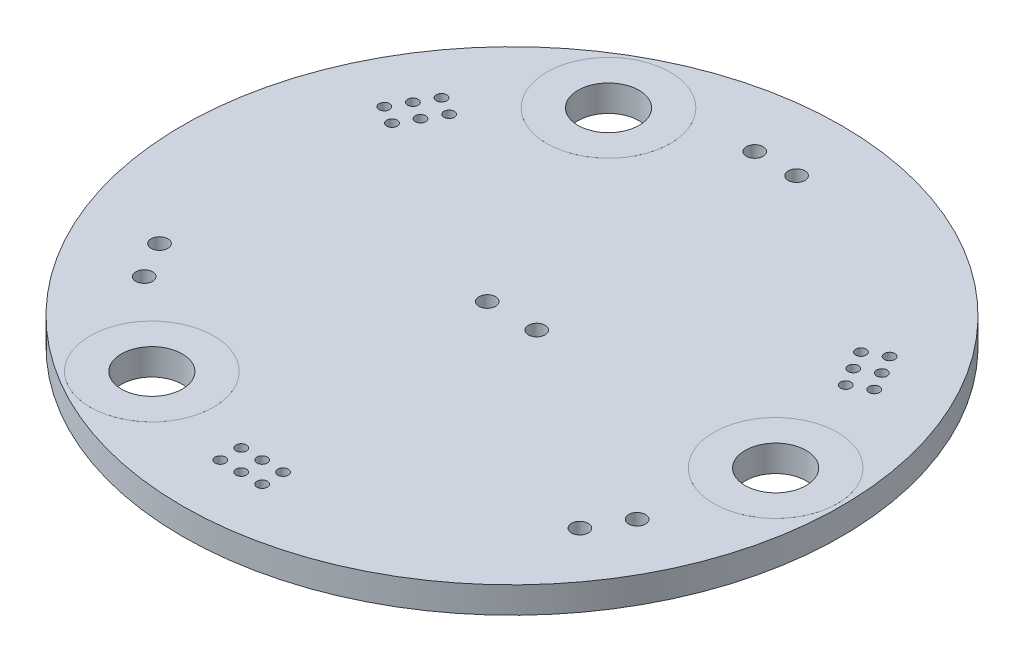
from build123d import *

# Parameters (mm, degrees)
SKETCH1_R           = 20
BOSS_EXTRUDE1_DEPTH = 1.6
SKETCH2_R           = 1.85
CUT_EXTRUDE1_DEPTH  = 29.329489935
SKETCH3_R           = 0.508
SKETCH3_R_2         = 0.3175
CUT_EXTRUDE2_DEPTH  = 29.329489935
BOSS_EXTRUDE2_START = 0.001
SKETCH5_R           = 3.75
SKETCH5_R_2         = 1.85
BOSS_EXTRUDE2_DEPTH = 0.001
BOSS_EXTRUDE3_DEPTH = 0.001


with BuildPart() as part:
    # Sketch1 → Boss-Extrude1 (new body)
    with BuildSketch(Plane(origin=(0, 0, 0), x_dir=(1, 0, 0), z_dir=(0, 1, 0))):
        Circle(SKETCH1_R)
    extrude(amount=BOSS_EXTRUDE1_DEPTH)

    # Sketch2 → Cut-Extrude1 (cut, through all)
    with BuildSketch(Plane(origin=(0, 1.6, 0), x_dir=(1, 0, 0), z_dir=(0, 1, 0))):
        with Locations((16, 0)):
            Circle(SKETCH2_R)
        with Locations((-8, -13.856406461)):
            Circle(SKETCH2_R)
        with Locations((-8, 13.856406461)):
            Circle(SKETCH2_R)
    extrude(amount=-CUT_EXTRUDE1_DEPTH, mode=Mode.SUBTRACT)

    # Sketch3 → Cut-Extrude2 (cut, through all)
    with BuildSketch(Plane(origin=(0, 1.6, 0), x_dir=(1, 0, 0), z_dir=(0, 1, 0))):
        with Locations((-1.5, 0)):
            Circle(SKETCH3_R)
        with Locations((1.5, 0)):
            Circle(SKETCH3_R)
        with Locations((1.27, 16)):
            Circle(SKETCH3_R)
        with Locations((-1.27, 16)):
            Circle(SKETCH3_R)
        with Locations((13.221406461, -9.099852263)):
            Circle(SKETCH3_R)
        with Locations((14.491406461, -6.900147737)):
            Circle(SKETCH3_R)
        with Locations((-14.491406461, -6.900147737)):
            Circle(SKETCH3_R)
        with Locations((-13.221406461, -9.099852263)):
            Circle(SKETCH3_R)
        with Locations((1.27, -16.4332)):
            Circle(SKETCH3_R_2)
        with Locations((1.27, -15.1632)):
            Circle(SKETCH3_R_2)
        with Locations((0, -15.1632)):
            Circle(SKETCH3_R_2)
        with Locations((-1.27, -15.1632)):
            Circle(SKETCH3_R_2)
        with Locations((0, -16.4332)):
            Circle(SKETCH3_R_2)
        with Locations((-1.27, -16.4332)):
            Circle(SKETCH3_R_2)
        with Locations((-14.866568665, 7.116747737)):
            Circle(SKETCH3_R_2)
        with Locations((-13.766716403, 6.481747737)):
            Circle(SKETCH3_R_2)
        with Locations((-13.131716403, 7.5816)):
            Circle(SKETCH3_R_2)
        with Locations((-12.496716403, 8.681452263)):
            Circle(SKETCH3_R_2)
        with Locations((-14.231568665, 8.2166)):
            Circle(SKETCH3_R_2)
        with Locations((-13.596568665, 9.316452263)):
            Circle(SKETCH3_R_2)
        with Locations((13.596568665, 9.316452263)):
            Circle(SKETCH3_R_2)
        with Locations((12.496716403, 8.681452263)):
            Circle(SKETCH3_R_2)
        with Locations((13.131716403, 7.5816)):
            Circle(SKETCH3_R_2)
        with Locations((13.766716403, 6.481747737)):
            Circle(SKETCH3_R_2)
        with Locations((14.231568665, 8.2166)):
            Circle(SKETCH3_R_2)
        with Locations((14.866568665, 7.116747737)):
            Circle(SKETCH3_R_2)
    extrude(amount=-CUT_EXTRUDE2_DEPTH, mode=Mode.SUBTRACT)

    # Sketch5 → Boss-Extrude2 (add)
    # profile 1 of 3: a face of its own
    with BuildSketch(Plane(origin=(0, 1.6, 0), x_dir=(1, 0, 0), z_dir=(0, 1, 0)).offset(BOSS_EXTRUDE2_START)):
        with Locations((-8, -13.856406461)):
            Circle(SKETCH5_R)
        with Locations((-8, -13.856406461)):
            Circle(SKETCH5_R_2, mode=Mode.SUBTRACT)
    # profile 2 of 3: a face of its own
    with BuildSketch(Plane(origin=(0, 1.6, 0), x_dir=(1, 0, 0), z_dir=(0, 1, 0)).offset(BOSS_EXTRUDE2_START)):
        with Locations((-8, 13.856406461)):
            Circle(SKETCH5_R)
        with Locations((-8, 13.856406461)):
            Circle(SKETCH5_R_2, mode=Mode.SUBTRACT)
    # profile 3 of 3: a face of its own
    with BuildSketch(Plane(origin=(0, 1.6, 0), x_dir=(1, 0, 0), z_dir=(0, 1, 0)).offset(BOSS_EXTRUDE2_START)):
        with Locations((16, 0)):
            Circle(SKETCH5_R)
        with Locations((16, 0)):
            Circle(SKETCH5_R_2, mode=Mode.SUBTRACT)
    boss_extrude2 = extrude(amount=-BOSS_EXTRUDE2_DEPTH)

    # Mirror1: Boss-Extrude2 across plane
    add(boss_extrude2.mirror(Plane.ZX.offset(0.8)))

    # Sketch6 → Boss-Extrude3 (add)
    # profile 1 of 7: a face of its own
    with BuildSketch(Plane(origin=(0, 0, 0), x_dir=(1, 0, 0), z_dir=(0, 1, 0))):
        with BuildLine():
            Line((-6.907051282, 6.560937956), (-7.394831731, 6.560937956))
            add(Edge.make_bspline(
                [(-7.394831731, 6.560937956), (-7.418709215, 6.56081242), (-7.464989723, 6.5605691), (-7.532289324, 6.556795435), (-7.595324189, 6.551649956), (-7.654112597, 6.543485604), (-7.708627385, 6.533634335), (-7.75903284, 6.521704466), (-7.805168677, 6.507399742), (-7.860249203, 6.484652399), (-7.923049675, 6.450850135), (-7.991048527, 6.40090116), (-8.049194413, 6.339806544), (-8.099327496, 6.270890361), (-8.139185439, 6.195079096), (-8.168020651, 6.114179675), (-8.186276277, 6.029235574), (-8.18815373, 5.970919018), (-8.189102564, 5.94144677)],
                knots=[0, 0, 0, 0, 1.001505555, 1.941167018, 2.826882275, 3.653841531, 4.429895133, 5.150066043, 5.825578002, 6.45369114, 7.647487171, 8.808567382, 9.977351308, 11.170798116, 12.373658725, 13.556498008, 14.765093433, 16, 16, 16, 16], degree=3))
            add(Edge.make_bspline(
                [(-8.189102564, 5.94144677), (-8.188321694, 5.913837802), (-8.18678721, 5.859583575), (-8.17211381, 5.78023064), (-8.149141904, 5.704694055), (-8.117209584, 5.633249494), (-8.075708158, 5.567511199), (-8.026523644, 5.506948866), (-7.967183071, 5.454126683), (-7.922723614, 5.424596038), (-7.900140224, 5.409595808)],
                knots=[0, 0, 0, 0, 1.044552857, 2.05264487, 3.044412934, 4.028983338, 5.005914585, 5.980388656, 6.974128949, 8, 8, 8, 8], degree=3))
            add(Edge.make_bspline(
                [(-7.900140224, 5.409595808), (-7.92854053, 5.398692238), (-7.982877349, 5.377831006), (-8.057653073, 5.340948532), (-8.122077962, 5.300832739), (-8.176647352, 5.257024274), (-8.223317105, 5.209803695), (-8.264069206, 5.158478613), (-8.298841617, 5.102379501), (-8.328636562, 5.042091261), (-8.351885673, 4.978229498), (-8.369297034, 4.911393229), (-8.379273783, 4.841822119), (-8.380693527, 4.794475419), (-8.381410256, 4.770573373)],
                knots=[0, 0, 0, 0, 1.27268992, 2.434971085, 3.483601985, 4.442670788, 5.356604649, 6.2567628, 7.179492994, 8.113709626, 9.066344395, 10.018646069, 10.999752585, 12, 12, 12, 12], degree=3))
            add(Edge.make_bspline(
                [(-8.381410256, 4.770573373), (-8.380712509, 4.746168464), (-8.379339672, 4.698151122), (-8.369211121, 4.627611741), (-8.352061759, 4.560201064), (-8.328439511, 4.495483077), (-8.297609287, 4.433582981), (-8.260089312, 4.374430649), (-8.215352481, 4.318620413), (-8.165307575, 4.265532111), (-8.108691756, 4.217797977), (-8.047609074, 4.175286758), (-7.981290274, 4.140325285), (-7.910824564, 4.110956698), (-7.835421481, 4.088522985), (-7.755419619, 4.072828289), (-7.670887975, 4.062253263), (-7.61288101, 4.061383831), (-7.583133013, 4.060937956)],
                knots=[0, 0, 0, 0, 0.978564426, 1.925352924, 2.850884081, 3.763762016, 4.682927383, 5.618979971, 6.567305752, 7.547517671, 8.540179244, 9.531824382, 10.526200242, 11.540722885, 12.589160233, 13.674978461, 14.80764778, 16, 16, 16, 16], degree=3))
            Line((-7.583133013, 4.060937956), (-6.907051282, 4.060937956))
            Line((-6.907051282, 4.060937956), (-6.907051282, 6.560937956))
        make_face()
        with BuildLine():
            Line((-7.131410256, 6.304527699), (-7.131410256, 5.503245648))
            Line((-7.131410256, 5.503245648), (-7.282151442, 5.503245648))
            add(Edge.make_bspline(
                [(-7.282151442, 5.503245648), (-7.304186296, 5.503531307), (-7.346762124, 5.504083259), (-7.408419193, 5.505664343), (-7.465651349, 5.510091517), (-7.518359801, 5.514517418), (-7.566461547, 5.521713552), (-7.609850019, 5.530279354), (-7.64920616, 5.539338572), (-7.69459155, 5.554745349), (-7.746072227, 5.577515117), (-7.800953016, 5.612852143), (-7.84933478, 5.654940966), (-7.890189914, 5.703505939), (-7.923626679, 5.756981786), (-7.946850761, 5.814515272), (-7.962598821, 5.874672509), (-7.964021343, 5.915971261), (-7.96474359, 5.936939558)],
                knots=[0, 0, 0, 0, 1.156816544, 2.235205308, 3.236616184, 4.169592532, 5.011045266, 5.787822928, 6.49130361, 7.128639758, 8.301311294, 9.436451833, 10.541879658, 11.654887649, 12.756523258, 13.837046038, 14.901820046, 16, 16, 16, 16], degree=3))
            add(Edge.make_bspline(
                [(-7.96474359, 5.936939558), (-7.964367747, 5.950815109), (-7.96363049, 5.978033518), (-7.957592416, 6.017711628), (-7.947329863, 6.055028594), (-7.934148225, 6.090495816), (-7.915727733, 6.12300428), (-7.894039545, 6.153677992), (-7.867835481, 6.181472362), (-7.838008829, 6.207450575), (-7.803716955, 6.230482381), (-7.764980318, 6.250654354), (-7.721274835, 6.266897766), (-7.673337081, 6.281123589), (-7.620429161, 6.291115228), (-7.563161623, 6.299439076), (-7.501065395, 6.303676749), (-7.458104608, 6.304237723), (-7.435897436, 6.304527699)],
                knots=[0, 0, 0, 0, 0.91205012, 1.789085906, 2.630437955, 3.453916878, 4.269457761, 5.079663411, 5.91843418, 6.774407191, 7.675494373, 8.627863946, 9.638891023, 10.736472738, 11.911756761, 13.175263542, 14.539845004, 16, 16, 16, 16], degree=3))
            Line((-7.435897436, 6.304527699), (-7.131410256, 6.304527699))
        make_face(mode=Mode.SUBTRACT)
        with BuildLine():
            Line((-7.131410256, 5.246835392), (-7.131410256, 4.317348212))
            Line((-7.131410256, 4.317348212), (-7.450921474, 4.317348212))
            add(Edge.make_bspline(
                [(-7.450921474, 4.317348212), (-7.473792136, 4.317622318), (-7.51787232, 4.318150619), (-7.581516056, 4.319875301), (-7.640503988, 4.323798355), (-7.694566942, 4.329973962), (-7.744288693, 4.336672854), (-7.789072767, 4.345680912), (-7.829282191, 4.356001598), (-7.875906697, 4.371954578), (-7.928409202, 4.396737772), (-7.984988386, 4.434105077), (-8.035292827, 4.478621725), (-8.078010869, 4.530143807), (-8.113020147, 4.586166183), (-8.138488329, 4.645555719), (-8.154196084, 4.707331095), (-8.156097633, 4.749450176), (-8.157051282, 4.770573373)],
                knots=[0, 0, 0, 0, 1.160039823, 2.235823828, 3.228722157, 4.157150951, 4.99529583, 5.772374946, 6.472645482, 7.099169577, 8.269452708, 9.405989375, 10.527446681, 11.663510218, 12.788923519, 13.866172445, 14.929861265, 16, 16, 16, 16], degree=3))
            add(Edge.make_bspline(
                [(-8.157051282, 4.770573373), (-8.156854065, 4.783782901), (-8.156462811, 4.809988888), (-8.150562372, 4.848500188), (-8.141981036, 4.885804383), (-8.130887155, 4.922002769), (-8.114730393, 4.956440895), (-8.095868575, 4.989799866), (-8.073753288, 5.02212378), (-8.039293169, 5.062989675), (-7.989170323, 5.110073256), (-7.917951198, 5.156171472), (-7.836970985, 5.193348477), (-7.778237062, 5.209133817), (-7.747896635, 5.217288116)],
                knots=[0, 0, 0, 0, 0.723448775, 1.435228256, 2.130040452, 2.821711965, 3.505591119, 4.210454504, 4.921174351, 5.648778258, 7.137944449, 8.670945889, 10.280296675, 12, 12, 12, 12], degree=3))
            add(Edge.make_bspline(
                [(-7.747896635, 5.217288116), (-7.735732995, 5.219756033), (-7.709359714, 5.225106987), (-7.6663543, 5.230755346), (-7.617257251, 5.235787532), (-7.561955196, 5.239509787), (-7.500378166, 5.243357318), (-7.432394653, 5.244853619), (-7.358282285, 5.246638805), (-7.306859162, 5.246768187), (-7.280148237, 5.246835392)],
                knots=[0, 0, 0, 0, 0.634451884, 1.375622551, 2.216452059, 3.157844607, 4.20941857, 5.370758133, 6.634282058, 8, 8, 8, 8], degree=3))
            Line((-7.280148237, 5.246835392), (-7.131410256, 5.246835392))
        make_face(mode=Mode.SUBTRACT)
    # profile 2 of 7: a face of its own
    with BuildSketch(Plane(origin=(0, 0, 0), x_dir=(1, 0, 0), z_dir=(0, 1, 0))):
        with BuildLine():
            Line((-6.394230769, 6.102203981), (-6.197916667, 5.951963597))
            add(Edge.make_bspline(
                [(-6.197916667, 5.951963597), (-6.183912461, 5.968653575), (-6.156092856, 6.001808515), (-6.111336283, 6.048365333), (-6.064692252, 6.091983376), (-6.016178594, 6.132870433), (-5.96492208, 6.169596695), (-5.912164367, 6.204076054), (-5.857022906, 6.234981581), (-5.780771667, 6.272455142), (-5.681023204, 6.311559539), (-5.555455462, 6.344347561), (-5.424376105, 6.36521983), (-5.334949249, 6.367480431), (-5.289463141, 6.368630264)],
                knots=[0, 0, 0, 0, 0.757959112, 1.505699292, 2.245454638, 2.979532153, 3.711538275, 4.438200793, 5.171680507, 5.909471876, 7.393775596, 8.890124382, 10.418191784, 12, 12, 12, 12], degree=3))
            add(Edge.make_bspline(
                [(-5.289463141, 6.368630264), (-5.264403641, 6.368341719), (-5.214517218, 6.367767308), (-5.140482594, 6.360189361), (-5.067830415, 6.349538497), (-4.996607939, 6.333734694), (-4.926905826, 6.313754252), (-4.858268396, 6.289878956), (-4.791689396, 6.260339785), (-4.726247797, 6.227691028), (-4.663548361, 6.190814282), (-4.604223327, 6.150590459), (-4.548489064, 6.107469676), (-4.496301484, 6.061290314), (-4.447607235, 6.012260342), (-4.402759156, 5.959857241), (-4.361912434, 5.904248546), (-4.324257416, 5.84616754), (-4.290534035, 5.785783404), (-4.262298407, 5.722872639), (-4.237294748, 5.658512565), (-4.217509575, 5.591976022), (-4.201849206, 5.523731189), (-4.191043732, 5.453594912), (-4.183551967, 5.381713712), (-4.182980412, 5.332992775), (-4.182692308, 5.308433949)],
                knots=[0, 0, 0, 0, 1.054917814, 2.100044995, 3.131103042, 4.146048494, 5.169673617, 6.183595914, 7.203665975, 8.234915748, 9.262203917, 10.264457458, 11.251630812, 12.227803204, 13.197192746, 14.159520551, 15.12972552, 16.100847026, 17.073214652, 18.039054194, 19.002613845, 19.979014051, 20.95965708, 21.949030935, 22.966165397, 24, 24, 24, 24], degree=3))
            add(Edge.make_bspline(
                [(-4.182692308, 5.308433949), (-4.183593607, 5.271483007), (-4.185363189, 5.198934732), (-4.201111999, 5.09267001), (-4.225044207, 4.990869529), (-4.260912476, 4.894169641), (-4.305140369, 4.801377957), (-4.36102652, 4.71406449), (-4.425752618, 4.630909801), (-4.500234347, 4.553879124), (-4.581952787, 4.483512178), (-4.669629866, 4.421547477), (-4.763047215, 4.369893989), (-4.861173379, 4.32691117), (-4.964763461, 4.29387065), (-5.073631177, 4.270610562), (-5.187539745, 4.255437576), (-5.26537503, 4.253984942), (-5.304987981, 4.253245648)],
                knots=[0, 0, 0, 0, 1.029171465, 2.020641659, 2.987623507, 3.938342917, 4.889210282, 5.84687017, 6.821220943, 7.821438502, 8.827599549, 9.822697543, 10.807740252, 11.797342354, 12.80366471, 13.83203677, 14.896651826, 16, 16, 16, 16], degree=3))
            add(Edge.make_bspline(
                [(-5.304987981, 4.253245648), (-5.348632759, 4.254451919), (-5.434536122, 4.25682615), (-5.560513284, 4.276939899), (-5.681110259, 4.309552698), (-5.796333535, 4.355194071), (-5.905858283, 4.414526419), (-6.009855897, 4.486453474), (-6.108414162, 4.571659426), (-6.167679363, 4.636718804), (-6.197916667, 4.669912315)],
                knots=[0, 0, 0, 0, 1.028121516, 2.023589091, 2.998037872, 3.967518031, 4.937445131, 5.927275754, 6.942489185, 8, 8, 8, 8], degree=3))
            Line((-6.197916667, 4.669912315), (-6.394230769, 4.521174334))
            add(Edge.make_bspline(
                [(-6.394230769, 4.521174334), (-6.378432119, 4.500789726), (-6.346910494, 4.46011815), (-6.295869053, 4.402781214), (-6.242099555, 4.34884976), (-6.18520262, 4.298758602), (-6.125832768, 4.251505412), (-6.062923974, 4.208432676), (-5.997303236, 4.168939187), (-5.929192894, 4.132777098), (-5.858665314, 4.10069335), (-5.785805003, 4.073226373), (-5.710926021, 4.049565738), (-5.634024943, 4.030100069), (-5.55494226, 4.014906437), (-5.47396335, 4.004749527), (-5.390913439, 3.997791017), (-5.334883852, 3.997156791), (-5.306490385, 3.996835392)],
                knots=[0, 0, 0, 0, 0.986787822, 1.968848986, 2.935600012, 3.899624008, 4.868462664, 5.837806735, 6.815139263, 7.798259679, 8.787526145, 9.778297419, 10.776456485, 11.791383307, 12.812564526, 13.85620153, 14.913611965, 16, 16, 16, 16], degree=3))
            add(Edge.make_bspline(
                [(-5.306490385, 3.996835392), (-5.279602051, 3.997022529), (-5.226433701, 3.997392571), (-5.147934593, 4.003386976), (-5.071513463, 4.011565359), (-4.997388731, 4.023879739), (-4.925155891, 4.03841141), (-4.85546976, 4.057890879), (-4.787644609, 4.079711712), (-4.721952937, 4.105358132), (-4.658338866, 4.134298262), (-4.597007572, 4.167006518), (-4.537987263, 4.20320785), (-4.480697677, 4.242104286), (-4.425985117, 4.284945216), (-4.373375456, 4.331135669), (-4.322573688, 4.380519963), (-4.291143198, 4.416130572), (-4.275340545, 4.434034911)],
                knots=[0, 0, 0, 0, 1.114604814, 2.203992996, 3.262667896, 4.300477797, 5.318619304, 6.316056647, 7.298880507, 8.271930387, 9.238335007, 10.195173496, 11.151986948, 12.108099108, 13.064862484, 14.031167946, 15.010108607, 16, 16, 16, 16], degree=3))
            add(Edge.make_bspline(
                [(-4.275340545, 4.434034911), (-4.250029371, 4.46513576), (-4.199712602, 4.526961982), (-4.135337114, 4.627166254), (-4.080231717, 4.731786403), (-4.035677488, 4.841372067), (-4.000846964, 4.955677343), (-3.976717539, 5.074759854), (-3.961037822, 5.198508384), (-3.959244758, 5.282677519), (-3.958333333, 5.325461193)],
                knots=[0, 0, 0, 0, 0.994628077, 1.977248131, 2.950237994, 3.925870899, 4.908910175, 5.911660606, 6.938484602, 8, 8, 8, 8], degree=3))
            add(Edge.make_bspline(
                [(-3.958333333, 5.325461193), (-3.959444186, 5.370429374), (-3.961629719, 5.458901463), (-3.980198144, 5.588740001), (-4.010068713, 5.713133857), (-4.052495062, 5.831850818), (-4.106284599, 5.945515304), (-4.17273218, 6.053259022), (-4.251065853, 6.155771021), (-4.340671258, 6.251495844), (-4.438933641, 6.339023953), (-4.544161365, 6.416028384), (-4.65614847, 6.480112324), (-4.773661221, 6.533681011), (-4.897579565, 6.574855628), (-5.027639114, 6.603679333), (-5.163595482, 6.62162013), (-5.256354358, 6.623888136), (-5.303485577, 6.62504052)],
                knots=[0, 0, 0, 0, 1.032925535, 2.032216505, 3.007276963, 3.968222605, 4.92396291, 5.891752235, 6.871517503, 7.883894988, 8.900124299, 9.891468569, 10.874487609, 11.85992873, 12.854644235, 13.869047385, 14.917252991, 16, 16, 16, 16], degree=3))
            add(Edge.make_bspline(
                [(-5.303485577, 6.62504052), (-5.3322102, 6.624696136), (-5.389067698, 6.624014461), (-5.473176735, 6.617367217), (-5.555064112, 6.60628607), (-5.634786242, 6.591203163), (-5.712730968, 6.572483647), (-5.788302568, 6.54809772), (-5.861944487, 6.520214483), (-5.933192279, 6.488101293), (-6.0017041, 6.452053621), (-6.067458614, 6.412471033), (-6.129933513, 6.3694026), (-6.189568404, 6.323214618), (-6.245365698, 6.272929932), (-6.298909611, 6.21993165), (-6.34838181, 6.162693204), (-6.378919806, 6.122403965), (-6.394230769, 6.102203981)],
                knots=[0, 0, 0, 0, 1.096760587, 2.17092713, 3.219439832, 4.250915756, 5.268269357, 6.278326846, 7.281116186, 8.274029601, 9.260640565, 10.235837813, 11.203064059, 12.156899882, 13.114053108, 14.069676657, 15.032185724, 16, 16, 16, 16], degree=3))
        make_face()
    # profile 3 of 7: a face of its own
    with BuildSketch(Plane(origin=(0, 0, 0), x_dir=(1, 0, 0), z_dir=(0, 1, 0))):
        with BuildLine():
            Line((-2.03525641, 6.560937956), (-2.525540865, 6.560937956))
            add(Edge.make_bspline(
                [(-2.525540865, 6.560937956), (-2.559262941, 6.560900887), (-2.623875936, 6.560829862), (-2.716529547, 6.558676472), (-2.800679356, 6.555800263), (-2.876143913, 6.551813197), (-2.943155412, 6.547101346), (-3.001410626, 6.540492747), (-3.051367452, 6.533592536), (-3.08130063, 6.526577245), (-3.094951923, 6.52337786)],
                knots=[0, 0, 0, 0, 1.415646017, 2.712440637, 3.8905458, 4.950247383, 5.884950622, 6.709939814, 7.411656543, 8, 8, 8, 8], degree=3))
            add(Edge.make_bspline(
                [(-3.094951923, 6.52337786), (-3.112233019, 6.518647896), (-3.146388002, 6.509299423), (-3.195603033, 6.490575335), (-3.242427208, 6.468373788), (-3.287021179, 6.443070974), (-3.328836952, 6.413581285), (-3.36849841, 6.38110013), (-3.405655539, 6.344877581), (-3.44009939, 6.305319909), (-3.471731389, 6.263091188), (-3.498966876, 6.217561024), (-3.521772038, 6.169495807), (-3.541331518, 6.118928971), (-3.555408986, 6.065435882), (-3.566013914, 6.009388231), (-3.572745077, 5.950792023), (-3.573389764, 5.910749261), (-3.573717949, 5.890365039)],
                knots=[0, 0, 0, 0, 0.999701418, 1.975846123, 2.934577507, 3.890451536, 4.834027766, 5.787354733, 6.749476667, 7.726910423, 8.712836071, 9.690891519, 10.682875813, 11.679750201, 12.712814741, 13.765529915, 14.8625177, 16, 16, 16, 16], degree=3))
            add(Edge.make_bspline(
                [(-3.573717949, 5.890365039), (-3.573416931, 5.869809484), (-3.57282797, 5.829591153), (-3.565759194, 5.770753447), (-3.556237629, 5.714526026), (-3.541596877, 5.661033561), (-3.522421397, 5.610593725), (-3.499927073, 5.562435702), (-3.47279598, 5.517378794), (-3.441621102, 5.475259424), (-3.406941391, 5.436038058), (-3.368903578, 5.399998919), (-3.327661227, 5.367352963), (-3.283345407, 5.338027003), (-3.235524086, 5.312701089), (-3.184922548, 5.2900173), (-3.131100964, 5.270966542), (-3.093856312, 5.26094507), (-3.074919872, 5.255849815)],
                knots=[0, 0, 0, 0, 1.121902311, 2.195077645, 3.232258892, 4.234102512, 5.217864754, 6.176164875, 7.132989551, 8.084763148, 9.034132444, 9.988522005, 10.94243251, 11.903244335, 12.886203696, 13.894208494, 14.929344452, 16, 16, 16, 16], degree=3))
            add(Edge.make_bspline(
                [(-3.074919872, 5.255849815), (-3.05925749, 5.252519114), (-3.024932471, 5.24521969), (-2.968401955, 5.237070792), (-2.902583822, 5.230115363), (-2.827567908, 5.224900265), (-2.743421547, 5.220435716), (-2.650099221, 5.216887077), (-2.547417737, 5.214937182), (-2.47579542, 5.214836615), (-2.438401442, 5.21478411)],
                knots=[0, 0, 0, 0, 0.601384939, 1.31797006, 2.144135048, 3.087295005, 4.142315834, 5.309527816, 6.595305764, 8, 8, 8, 8], degree=3))
            Line((-2.438401442, 5.21478411), (-2.259615385, 5.21478411))
            Line((-2.259615385, 5.21478411), (-2.259615385, 4.060937956))
            Line((-2.259615385, 4.060937956), (-2.03525641, 4.060937956))
            Line((-2.03525641, 4.060937956), (-2.03525641, 6.560937956))
        make_face()
        with BuildLine():
            Line((-2.259615385, 6.304527699), (-2.259615385, 5.471194366))
            Line((-2.259615385, 5.471194366), (-2.697315705, 5.465685552))
            add(Edge.make_bspline(
                [(-2.697315705, 5.465685552), (-2.718687081, 5.465674507), (-2.759944081, 5.465653184), (-2.819541383, 5.468499772), (-2.874833731, 5.471785867), (-2.925651285, 5.47659724), (-2.972016952, 5.483398139), (-3.014008044, 5.490263666), (-3.051298961, 5.500196068), (-3.094941248, 5.513569688), (-3.14357221, 5.5363787), (-3.196477602, 5.569485764), (-3.241313735, 5.61168627), (-3.280112519, 5.659134721), (-3.310902431, 5.711919813), (-3.333442426, 5.768397625), (-3.34668611, 5.827988946), (-3.348461962, 5.868766188), (-3.349358974, 5.889363437)],
                knots=[0, 0, 0, 0, 1.160613943, 2.240541288, 3.23993089, 4.169200891, 5.011653406, 5.7853311, 6.478053781, 7.106038997, 8.262395093, 9.384106736, 10.481365981, 11.59014053, 12.70357646, 13.786202915, 14.881775077, 16, 16, 16, 16], degree=3))
            add(Edge.make_bspline(
                [(-3.349358974, 5.889363437), (-3.348457084, 5.909462375), (-3.346664238, 5.949416576), (-3.333338621, 6.007972834), (-3.310946254, 6.06385548), (-3.279905829, 6.115979112), (-3.242233594, 6.163256829), (-3.198448349, 6.204326206), (-3.148653162, 6.237341708), (-3.102332997, 6.258651195), (-3.061189293, 6.271662106), (-3.025452178, 6.280765563), (-2.985101697, 6.288033853), (-2.940124711, 6.293919213), (-2.89086983, 6.298957399), (-2.836913891, 6.302375954), (-2.778461288, 6.304376994), (-2.737882309, 6.304476248), (-2.716846955, 6.304527699)],
                knots=[0, 0, 0, 0, 1.120700087, 2.227813068, 3.331159281, 4.466773991, 5.599788987, 6.693661531, 7.80175334, 8.91857717, 9.525282508, 10.207424825, 10.974604443, 11.810962634, 12.737642355, 13.736264703, 14.826523623, 16, 16, 16, 16], degree=3))
            Line((-2.716846955, 6.304527699), (-2.259615385, 6.304527699))
        make_face(mode=Mode.SUBTRACT)
    # profile 4 of 7: a face of its own
    with BuildSketch(Plane(origin=(0, 0, 0), x_dir=(1, 0, 0), z_dir=(0, 1, 0))):
        with BuildLine():
            Line((1.105769231, 5.887861033), (0.881410256, 5.887861033))
            Line((0.881410256, 5.887861033), (0.881410256, 5.558333789))
            add(Edge.make_bspline(
                [(0.881410256, 5.558333789), (0.857454803, 5.588221448), (0.810968409, 5.646219494), (0.733551028, 5.722448476), (0.651733957, 5.785266493), (0.56601824, 5.835340632), (0.476287518, 5.873088222), (0.383088754, 5.900349601), (0.285863964, 5.916695907), (0.219746509, 5.918831786), (0.186298077, 5.919912315)],
                knots=[0, 0, 0, 0, 1.12780773, 2.188550248, 3.19190651, 4.159438251, 5.104880172, 6.052711206, 7.014878035, 8, 8, 8, 8], degree=3))
            add(Edge.make_bspline(
                [(0.186298077, 5.919912315), (0.152490481, 5.918665747), (0.086320861, 5.916225912), (-0.010020611, 5.896928276), (-0.100001607, 5.863967379), (-0.183301289, 5.8188159), (-0.258392156, 5.762668419), (-0.324338478, 5.697255718), (-0.378883655, 5.622015658), (-0.4154532, 5.552213404), (-0.439542949, 5.490292837), (-0.454708904, 5.437259444), (-0.467588176, 5.37817505), (-0.478753711, 5.313218201), (-0.486308791, 5.241933779), (-0.49226757, 5.164613999), (-0.496538066, 5.081283906), (-0.4967075, 5.023650601), (-0.496794872, 4.993930744)],
                knots=[0, 0, 0, 0, 1.235846778, 2.418850247, 3.575807741, 4.728682307, 5.871620074, 6.994088408, 8.11269785, 9.256955736, 9.865816715, 10.540099792, 11.271859618, 12.076849838, 12.949306005, 13.892391288, 14.913166135, 16, 16, 16, 16], degree=3))
            Line((-0.496794872, 4.993930744), (-0.496794872, 4.060937956))
            Line((-0.496794872, 4.060937956), (-0.272435897, 4.060937956))
            Line((-0.272435897, 4.060937956), (-0.272435897, 4.920312956))
            add(Edge.make_bspline(
                [(-0.272435897, 4.920312956), (-0.272297892, 4.945186131), (-0.27203391, 4.992764281), (-0.271201305, 5.060885012), (-0.269194301, 5.12266114), (-0.266374077, 5.177944973), (-0.262246198, 5.226683428), (-0.257944319, 5.268975769), (-0.252683621, 5.304768299), (-0.247995826, 5.326314786), (-0.245893429, 5.33597802)],
                knots=[0, 0, 0, 0, 1.430800155, 2.736877192, 3.918605307, 4.986035426, 5.920637409, 6.731861385, 7.431261377, 8, 8, 8, 8], degree=3))
            add(Edge.make_bspline(
                [(-0.245893429, 5.33597802), (-0.238303764, 5.364343152), (-0.223696007, 5.418937255), (-0.187600304, 5.492990364), (-0.142018747, 5.55598907), (-0.086377426, 5.607543871), (-0.0212138, 5.647665897), (0.053291302, 5.675504436), (0.136418902, 5.692916057), (0.194886319, 5.694649723), (0.225360577, 5.69555334)],
                knots=[0, 0, 0, 0, 1.084156227, 2.086665306, 3.027808233, 3.945421172, 4.874247719, 5.839848303, 6.874090471, 8, 8, 8, 8], degree=3))
            add(Edge.make_bspline(
                [(0.225360577, 5.69555334), (0.243408922, 5.695213337), (0.279126132, 5.694540479), (0.332090397, 5.687789552), (0.383464807, 5.676747798), (0.433764956, 5.661841629), (0.481984809, 5.641368579), (0.529673588, 5.618133315), (0.575035562, 5.589170306), (0.619037989, 5.556891291), (0.659975709, 5.521120428), (0.698067379, 5.48337435), (0.732023108, 5.44317749), (0.762786447, 5.401177527), (0.78934235, 5.356797643), (0.812523127, 5.310465996), (0.83219148, 5.262121604), (0.841964832, 5.228567988), (0.846854968, 5.211779302)],
                knots=[0, 0, 0, 0, 1.023777757, 2.026029729, 3.023749952, 4.003683103, 4.997618607, 5.993177895, 7.010360494, 8.046726602, 9.087585522, 10.09234134, 11.086953743, 12.070360549, 13.043493632, 14.017870808, 15.008233677, 16, 16, 16, 16], degree=3))
            add(Edge.make_bspline(
                [(0.846854968, 5.211779302), (0.849669003, 5.199454157), (0.855795009, 5.172622961), (0.862411566, 5.128591233), (0.868416977, 5.077655536), (0.873443376, 5.01987531), (0.876518674, 4.955048256), (0.879871814, 4.883451229), (0.881092572, 4.804798738), (0.881301396, 4.750040386), (0.881410256, 4.721494847)],
                knots=[0, 0, 0, 0, 0.615963638, 1.340920617, 2.168419149, 3.115676021, 4.16674242, 5.331190069, 6.6087489, 8, 8, 8, 8], degree=3))
            Line((0.881410256, 4.721494847), (0.881410256, 4.060937956))
            Line((0.881410256, 4.060937956), (1.105769231, 4.060937956))
            Line((1.105769231, 4.060937956), (1.105769231, 5.887861033))
        make_face()
    # profile 5 of 7: a face of its own
    with BuildSketch(Plane(origin=(0, 0, 0), x_dir=(1, 0, 0), z_dir=(0, 1, 0))):
        with BuildLine():
            Line((3.221153846, 5.887861033), (2.996794872, 5.887861033))
            Line((2.996794872, 5.887861033), (2.996794872, 5.558333789))
            add(Edge.make_bspline(
                [(2.996794872, 5.558333789), (2.972839418, 5.588221448), (2.926353025, 5.646219494), (2.848935644, 5.722448476), (2.767118572, 5.785266493), (2.681402855, 5.835340632), (2.591672134, 5.873088222), (2.498473369, 5.900349601), (2.401248579, 5.916695907), (2.335131124, 5.918831786), (2.301682692, 5.919912315)],
                knots=[0, 0, 0, 0, 1.12780773, 2.188550248, 3.19190651, 4.159438251, 5.104880172, 6.052711206, 7.014878035, 8, 8, 8, 8], degree=3))
            add(Edge.make_bspline(
                [(2.301682692, 5.919912315), (2.267875097, 5.918665747), (2.201705477, 5.916225912), (2.105364004, 5.896928276), (2.015383009, 5.863967379), (1.932083326, 5.8188159), (1.856992459, 5.762668419), (1.791046137, 5.697255718), (1.73650096, 5.622015658), (1.699931415, 5.552213404), (1.675841667, 5.490292837), (1.660675711, 5.437259444), (1.647796439, 5.37817505), (1.636630905, 5.313218201), (1.629075825, 5.241933779), (1.623117045, 5.164613999), (1.618846549, 5.081283906), (1.618677116, 5.023650601), (1.618589744, 4.993930744)],
                knots=[0, 0, 0, 0, 1.235846778, 2.418850247, 3.575807741, 4.728682307, 5.871620074, 6.994088408, 8.11269785, 9.256955736, 9.865816715, 10.540099792, 11.271859618, 12.076849838, 12.949306005, 13.892391288, 14.913166135, 16, 16, 16, 16], degree=3))
            Line((1.618589744, 4.993930744), (1.618589744, 4.060937956))
            Line((1.618589744, 4.060937956), (1.842948718, 4.060937956))
            Line((1.842948718, 4.060937956), (1.842948718, 4.920312956))
            add(Edge.make_bspline(
                [(1.842948718, 4.920312956), (1.843086724, 4.945186131), (1.843350705, 4.992764281), (1.84418331, 5.060885012), (1.846190315, 5.12266114), (1.849010538, 5.177944973), (1.853138417, 5.226683428), (1.857440297, 5.268975769), (1.862700994, 5.304768299), (1.867388789, 5.326314786), (1.869491186, 5.33597802)],
                knots=[0, 0, 0, 0, 1.430800155, 2.736877192, 3.918605307, 4.986035426, 5.920637409, 6.731861385, 7.431261377, 8, 8, 8, 8], degree=3))
            add(Edge.make_bspline(
                [(1.869491186, 5.33597802), (1.877080851, 5.364343152), (1.891688609, 5.418937255), (1.927784311, 5.492990364), (1.973365869, 5.55598907), (2.02900719, 5.607543871), (2.094170815, 5.647665897), (2.168675917, 5.675504436), (2.251803518, 5.692916057), (2.310270934, 5.694649723), (2.340745192, 5.69555334)],
                knots=[0, 0, 0, 0, 1.084156227, 2.086665306, 3.027808233, 3.945421172, 4.874247719, 5.839848303, 6.874090471, 8, 8, 8, 8], degree=3))
            add(Edge.make_bspline(
                [(2.340745192, 5.69555334), (2.358793538, 5.695213337), (2.394510747, 5.694540479), (2.447475013, 5.687789552), (2.498849422, 5.676747798), (2.549149571, 5.661841629), (2.597369424, 5.641368579), (2.645058203, 5.618133315), (2.690420178, 5.589170306), (2.734422604, 5.556891291), (2.775360324, 5.521120428), (2.813451994, 5.48337435), (2.847407723, 5.44317749), (2.878171063, 5.401177527), (2.904726965, 5.356797643), (2.927907742, 5.310465996), (2.947576096, 5.262121604), (2.957349447, 5.228567988), (2.962239583, 5.211779302)],
                knots=[0, 0, 0, 0, 1.023777757, 2.026029729, 3.023749952, 4.003683103, 4.997618607, 5.993177895, 7.010360494, 8.046726602, 9.087585522, 10.09234134, 11.086953743, 12.070360549, 13.043493632, 14.017870808, 15.008233677, 16, 16, 16, 16], degree=3))
            add(Edge.make_bspline(
                [(2.962239583, 5.211779302), (2.965053618, 5.199454157), (2.971179624, 5.172622961), (2.977796181, 5.128591233), (2.983801592, 5.077655536), (2.988827991, 5.01987531), (2.991903289, 4.955048256), (2.995256429, 4.883451229), (2.996477187, 4.804798738), (2.996686012, 4.750040386), (2.996794872, 4.721494847)],
                knots=[0, 0, 0, 0, 0.615963638, 1.340920617, 2.168419149, 3.115676021, 4.16674242, 5.331190069, 6.6087489, 8, 8, 8, 8], degree=3))
            Line((2.996794872, 4.721494847), (2.996794872, 4.060937956))
            Line((2.996794872, 4.060937956), (3.221153846, 4.060937956))
            Line((3.221153846, 4.060937956), (3.221153846, 5.887861033))
        make_face()
    # profile 6 of 7: a face of its own
    with BuildSketch(Plane(origin=(0, 0, 0), x_dir=(1, 0, 0), z_dir=(0, 1, 0))):
        with BuildLine():
            add(Edge.make_bspline(
                [(4.614383013, 5.919912315), (4.580103532, 5.919182393), (4.512889848, 5.917751193), (4.414455644, 5.902454789), (4.320494833, 5.879063815), (4.230647553, 5.846726985), (4.146064484, 5.803382734), (4.065513596, 5.751661812), (3.989215732, 5.690388531), (3.943484997, 5.642989911), (3.920272436, 5.618930744)],
                knots=[0, 0, 0, 0, 1.054011418, 2.066658804, 3.057071809, 4.030435133, 4.997543892, 5.974964718, 6.972108034, 8, 8, 8, 8], degree=3))
            add(Edge.make_bspline(
                [(3.920272436, 5.618930744), (3.900285326, 5.595920754), (3.860697911, 5.550346081), (3.809936684, 5.476449215), (3.766206998, 5.399920572), (3.731162026, 5.31974391), (3.703529866, 5.236619145), (3.683911511, 5.150260565), (3.672242272, 5.060858889), (3.670668724, 5.000141862), (3.669871795, 4.969391481)],
                knots=[0, 0, 0, 0, 1.025258237, 2.030674902, 3.01204498, 3.988269485, 4.97094183, 5.956517959, 6.965070386, 8, 8, 8, 8], degree=3))
            add(Edge.make_bspline(
                [(3.669871795, 4.969391481), (3.67057275, 4.938462869), (3.67195787, 4.877346488), (3.685060453, 4.787332655), (3.705439801, 4.700050639), (3.734605399, 4.615865858), (3.772004049, 4.534520981), (3.817640254, 4.456371303), (3.871834266, 4.381262636), (3.933265693, 4.309832752), (4.00115989, 4.243999741), (4.074814281, 4.186622406), (4.152781448, 4.137464174), (4.236098129, 4.097866734), (4.324003477, 4.06664552), (4.416687097, 4.044716937), (4.514005005, 4.031458591), (4.58045302, 4.029756039), (4.614383013, 4.028886674)],
                knots=[0, 0, 0, 0, 0.998656419, 1.973391657, 2.932242238, 3.890759089, 4.846373663, 5.82037756, 6.809684879, 7.83454468, 8.860553229, 9.859544525, 10.845671541, 11.83227036, 12.833544569, 13.85385346, 14.904124723, 16, 16, 16, 16], degree=3))
            add(Edge.make_bspline(
                [(4.614383013, 4.028886674), (4.648479241, 4.029758957), (4.715258427, 4.031467367), (4.812919842, 4.044665426), (4.90576957, 4.066635414), (4.993789998, 4.097969337), (5.077464888, 4.13746544), (5.155883815, 4.18647379), (5.22959804, 4.244016758), (5.2975066, 4.309828141), (5.358934176, 4.381263824), (5.413129181, 4.456370995), (5.458765129, 4.534521061), (5.496163846, 4.615865836), (5.525329426, 4.700050645), (5.545708778, 4.787332654), (5.55881136, 4.877346488), (5.560196481, 4.938462869), (5.560897436, 4.969391481)],
                knots=[0, 0, 0, 0, 1.099876186, 2.154163076, 3.173186993, 4.173200201, 5.163417411, 6.152872554, 7.150605724, 8.17532212, 9.198891216, 10.186952605, 11.159729845, 12.11414092, 13.071450619, 14.029093627, 15.002601286, 16, 16, 16, 16], degree=3))
            add(Edge.make_bspline(
                [(5.560897436, 4.969391481), (5.560095071, 4.999974729), (5.558506527, 5.060524302), (5.546849021, 5.149757916), (5.527307195, 5.235970337), (5.499641912, 5.318774249), (5.464273918, 5.39859956), (5.421158713, 5.475317297), (5.369879689, 5.548880011), (5.330449724, 5.594395783), (5.310496795, 5.61742834)],
                knots=[0, 0, 0, 0, 1.031353054, 2.041901799, 3.029428768, 4.008703097, 4.981709435, 5.96992636, 6.972712378, 8, 8, 8, 8], degree=3))
            add(Edge.make_bspline(
                [(5.310496795, 5.61742834), (5.28731923, 5.641696154), (5.24173647, 5.68942308), (5.165058807, 5.75051774), (5.084706078, 5.803314936), (4.999188274, 5.845797947), (4.909414804, 5.879254031), (4.814972487, 5.902515113), (4.716204262, 5.917696081), (4.648661676, 5.919166208), (4.614383013, 5.919912315)],
                knots=[0, 0, 0, 0, 1.027980169, 2.021703884, 2.998553061, 3.971491411, 4.943284454, 5.930300938, 6.949603206, 8, 8, 8, 8], degree=3))
        make_face()
        with BuildLine():
            add(Edge.make_bspline(
                [(4.615384615, 5.69555334), (4.639625766, 5.694864346), (4.687482287, 5.693504145), (4.757924847, 5.683158498), (4.825739243, 5.666767424), (4.891054132, 5.643478812), (4.953649255, 5.61340817), (5.013584542, 5.576473627), (5.071036285, 5.533164373), (5.124880616, 5.483548179), (5.174296553, 5.429348897), (5.217495108, 5.371600069), (5.254227327, 5.311238393), (5.28482744, 5.2482011), (5.307618289, 5.181849375), (5.324170448, 5.112934639), (5.334506334, 5.041316484), (5.335853747, 4.992630042), (5.336538462, 4.967889078)],
                knots=[0, 0, 0, 0, 1.021534396, 2.016698045, 2.994645724, 3.958388632, 4.93408049, 5.916473867, 6.921342795, 7.962252576, 8.998418191, 10.008913653, 10.997312074, 11.973003931, 12.956656626, 13.948281152, 14.957379055, 16, 16, 16, 16], degree=3))
            add(Edge.make_bspline(
                [(5.336538462, 4.967889078), (5.33539073, 4.935923344), (5.333112699, 4.87247734), (5.31458753, 4.779040824), (5.28359733, 4.689339501), (5.241749273, 4.603899225), (5.18931626, 4.524847598), (5.127539783, 4.454367966), (5.057082855, 4.393520958), (4.978785354, 4.34303464), (4.894246556, 4.302920529), (4.804777755, 4.274492689), (4.711462974, 4.256012909), (4.647691023, 4.254176141), (4.615384615, 4.253245648)],
                knots=[0, 0, 0, 0, 1.016792936, 2.018143844, 3.017858371, 4.030088057, 5.03801393, 6.028138512, 7.003788237, 7.991172063, 8.984598303, 9.972568034, 10.972917682, 12, 12, 12, 12], degree=3))
            add(Edge.make_bspline(
                [(4.615384615, 4.253245648), (4.583080066, 4.254181563), (4.519311783, 4.256029032), (4.426126657, 4.274399617), (4.336902391, 4.303045089), (4.2524514, 4.342989525), (4.174189541, 4.393712678), (4.103225883, 4.454024376), (4.041976875, 4.52503427), (3.989595728, 4.604003933), (3.947062341, 4.689207042), (3.916217197, 4.779057379), (3.897647492, 4.872473124), (3.895375472, 4.935921931), (3.894230769, 4.967889078)],
                knots=[0, 0, 0, 0, 1.02726834, 2.027799167, 3.010890988, 4.004497153, 4.992059811, 5.971914811, 6.958719428, 7.966827853, 8.981595046, 9.981490638, 10.983022906, 12, 12, 12, 12], degree=3))
            add(Edge.make_bspline(
                [(3.894230769, 4.967889078), (3.894915248, 4.99263019), (3.896262197, 5.041316923), (3.906601457, 5.112932961), (3.923141129, 5.18185553), (3.945977998, 5.24817839), (3.976445151, 5.311401607), (4.013885717, 5.371422841), (4.056907878, 5.429548945), (4.106920108, 5.483372974), (4.160708235, 5.533183715), (4.218183262, 5.576490421), (4.278029675, 5.613245847), (4.340442949, 5.643736018), (4.405766211, 5.666555547), (4.473485589, 5.683253141), (4.543627596, 5.693460424), (4.591312627, 5.69485124), (4.615384615, 5.69555334)],
                knots=[0, 0, 0, 0, 1.042956736, 2.052379634, 3.044323526, 4.02829302, 5.004299113, 5.996692471, 7.007513377, 8.048758398, 9.090003419, 10.095195979, 11.07790575, 12.047570684, 13.018257071, 13.989683339, 14.985167495, 16, 16, 16, 16], degree=3))
        make_face(mode=Mode.SUBTRACT)
    # profile 7 of 7: a face of its own
    with BuildSketch(Plane(origin=(0, 0, 0), x_dir=(1, 0, 0), z_dir=(0, 1, 0))):
        with BuildLine():
            Line((5.945512821, 6.102203981), (6.141826923, 5.951963597))
            add(Edge.make_bspline(
                [(6.141826923, 5.951963597), (6.155831129, 5.968653575), (6.183650734, 6.001808515), (6.228407307, 6.048365333), (6.275051338, 6.091983376), (6.323564996, 6.132870433), (6.37482151, 6.169596695), (6.427579223, 6.204076054), (6.482720684, 6.234981581), (6.558971923, 6.272455142), (6.658720386, 6.311559539), (6.784288128, 6.344347561), (6.915367484, 6.36521983), (7.004794341, 6.367480431), (7.050280449, 6.368630264)],
                knots=[0, 0, 0, 0, 0.757959112, 1.505699292, 2.245454638, 2.979532153, 3.711538275, 4.438200793, 5.171680507, 5.909471876, 7.393775596, 8.890124382, 10.418191784, 12, 12, 12, 12], degree=3))
            add(Edge.make_bspline(
                [(7.050280449, 6.368630264), (7.075339948, 6.368341719), (7.125226372, 6.367767308), (7.199260995, 6.360189361), (7.271913175, 6.349538497), (7.343135651, 6.333734694), (7.412837764, 6.313754252), (7.481475194, 6.289878956), (7.548054194, 6.260339785), (7.613495793, 6.227691028), (7.676195229, 6.190814282), (7.735520263, 6.150590459), (7.791254526, 6.107469676), (7.843442106, 6.061290314), (7.892136355, 6.012260342), (7.936984434, 5.959857241), (7.977831156, 5.904248546), (8.015486173, 5.84616754), (8.049209554, 5.785783404), (8.077445183, 5.722872639), (8.102448841, 5.658512565), (8.122234015, 5.591976022), (8.137894384, 5.523731189), (8.148699858, 5.453594912), (8.156191623, 5.381713712), (8.156763178, 5.332992775), (8.157051282, 5.308433949)],
                knots=[0, 0, 0, 0, 1.054917814, 2.100044995, 3.131103042, 4.146048494, 5.169673617, 6.183595914, 7.203665975, 8.234915748, 9.262203917, 10.264457458, 11.251630812, 12.227803204, 13.197192746, 14.159520551, 15.12972552, 16.100847026, 17.073214652, 18.039054194, 19.002613845, 19.979014051, 20.95965708, 21.949030935, 22.966165397, 24, 24, 24, 24], degree=3))
            add(Edge.make_bspline(
                [(8.157051282, 5.308433949), (8.156149983, 5.271483007), (8.154380401, 5.198934732), (8.138631591, 5.09267001), (8.114699383, 4.990869529), (8.078831114, 4.894169641), (8.034603221, 4.801377957), (7.978717069, 4.71406449), (7.913990971, 4.630909801), (7.839509243, 4.553879124), (7.757790803, 4.483512178), (7.670113723, 4.421547477), (7.576696375, 4.369893989), (7.478570211, 4.32691117), (7.374980129, 4.29387065), (7.266112413, 4.270610562), (7.152203845, 4.255437576), (7.07436856, 4.253984942), (7.034755609, 4.253245648)],
                knots=[0, 0, 0, 0, 1.029171465, 2.020641659, 2.987623507, 3.938342917, 4.889210282, 5.84687017, 6.821220943, 7.821438502, 8.827599549, 9.822697543, 10.807740252, 11.797342354, 12.80366471, 13.83203677, 14.896651826, 16, 16, 16, 16], degree=3))
            add(Edge.make_bspline(
                [(7.034755609, 4.253245648), (6.991110831, 4.254451919), (6.905207468, 4.25682615), (6.779230306, 4.276939899), (6.65863333, 4.309552698), (6.543410054, 4.355194071), (6.433885307, 4.414526419), (6.329887693, 4.486453474), (6.231329428, 4.571659426), (6.172064226, 4.636718804), (6.141826923, 4.669912315)],
                knots=[0, 0, 0, 0, 1.028121516, 2.023589091, 2.998037872, 3.967518031, 4.937445131, 5.927275754, 6.942489185, 8, 8, 8, 8], degree=3))
            Line((6.141826923, 4.669912315), (5.945512821, 4.521174334))
            add(Edge.make_bspline(
                [(5.945512821, 4.521174334), (5.96131147, 4.500789726), (5.992833096, 4.46011815), (6.043874536, 4.402781214), (6.097644034, 4.34884976), (6.15454097, 4.298758602), (6.213910821, 4.251505412), (6.276819616, 4.208432676), (6.342440353, 4.168939187), (6.410550695, 4.132777098), (6.481078276, 4.10069335), (6.553938587, 4.073226373), (6.628817569, 4.049565738), (6.705718647, 4.030100069), (6.78480133, 4.014906437), (6.86578024, 4.004749527), (6.948830151, 3.997791017), (7.004859738, 3.997156791), (7.033253205, 3.996835392)],
                knots=[0, 0, 0, 0, 0.986787822, 1.968848986, 2.935600012, 3.899624008, 4.868462664, 5.837806735, 6.815139263, 7.798259679, 8.787526145, 9.778297419, 10.776456485, 11.791383307, 12.812564526, 13.85620153, 14.913611965, 16, 16, 16, 16], degree=3))
            add(Edge.make_bspline(
                [(7.033253205, 3.996835392), (7.060141539, 3.997022529), (7.113309889, 3.997392571), (7.191808997, 4.003386976), (7.268230126, 4.011565359), (7.342354859, 4.023879739), (7.414587698, 4.03841141), (7.48427383, 4.057890879), (7.55209898, 4.079711712), (7.617790652, 4.105358132), (7.681404724, 4.134298262), (7.742736017, 4.167006518), (7.801756326, 4.20320785), (7.859045913, 4.242104286), (7.913758472, 4.284945216), (7.966368133, 4.331135669), (8.017169902, 4.380519963), (8.048600391, 4.416130572), (8.064403045, 4.434034911)],
                knots=[0, 0, 0, 0, 1.114604814, 2.203992996, 3.262667896, 4.300477797, 5.318619304, 6.316056647, 7.298880507, 8.271930387, 9.238335007, 10.195173496, 11.151986948, 12.108099108, 13.064862484, 14.031167946, 15.010108607, 16, 16, 16, 16], degree=3))
            add(Edge.make_bspline(
                [(8.064403045, 4.434034911), (8.089714219, 4.46513576), (8.140030988, 4.526961982), (8.204406476, 4.627166254), (8.259511873, 4.731786403), (8.304066102, 4.841372067), (8.338896626, 4.955677343), (8.363026051, 5.074759854), (8.378705768, 5.198508384), (8.380498832, 5.282677519), (8.381410256, 5.325461193)],
                knots=[0, 0, 0, 0, 0.994628077, 1.977248131, 2.950237994, 3.925870899, 4.908910175, 5.911660606, 6.938484602, 8, 8, 8, 8], degree=3))
            add(Edge.make_bspline(
                [(8.381410256, 5.325461193), (8.380299404, 5.370429374), (8.378113871, 5.458901463), (8.359545446, 5.588740001), (8.329674877, 5.713133857), (8.287248528, 5.831850818), (8.233458991, 5.945515304), (8.16701141, 6.053259022), (8.088677737, 6.155771021), (7.999072331, 6.251495844), (7.900809949, 6.339023953), (7.795582225, 6.416028384), (7.68359512, 6.480112324), (7.566082369, 6.533681011), (7.442164025, 6.574855628), (7.312104475, 6.603679333), (7.176148108, 6.62162013), (7.083389232, 6.623888136), (7.036258013, 6.62504052)],
                knots=[0, 0, 0, 0, 1.032925535, 2.032216505, 3.007276963, 3.968222605, 4.92396291, 5.891752235, 6.871517503, 7.883894988, 8.900124299, 9.891468569, 10.874487609, 11.85992873, 12.854644235, 13.869047385, 14.917252991, 16, 16, 16, 16], degree=3))
            add(Edge.make_bspline(
                [(7.036258013, 6.62504052), (7.00753339, 6.624696136), (6.950675892, 6.624014461), (6.866566854, 6.617367217), (6.784679478, 6.60628607), (6.704957348, 6.591203163), (6.627012622, 6.572483647), (6.551441022, 6.54809772), (6.477799102, 6.520214483), (6.406551311, 6.488101293), (6.338039489, 6.452053621), (6.272284976, 6.412471033), (6.209810077, 6.3694026), (6.150175185, 6.323214618), (6.094377892, 6.272929932), (6.040833978, 6.21993165), (5.99136178, 6.162693204), (5.960823783, 6.122403965), (5.945512821, 6.102203981)],
                knots=[0, 0, 0, 0, 1.096760587, 2.17092713, 3.219439832, 4.250915756, 5.268269357, 6.278326846, 7.281116186, 8.274029601, 9.260640565, 10.235837813, 11.203064059, 12.156899882, 13.114053108, 14.069676657, 15.032185724, 16, 16, 16, 16], degree=3))
        make_face()
    extrude(amount=-BOSS_EXTRUDE3_DEPTH)


solid = part.part
